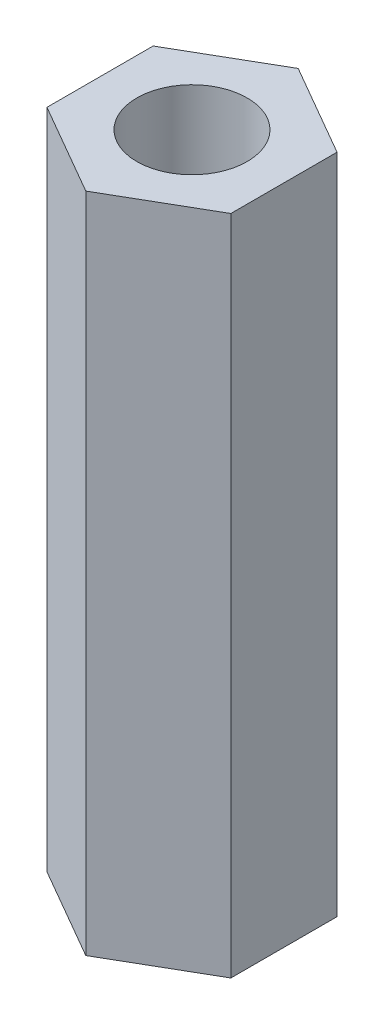
from build123d import *

# Parameters (mm, degrees)
SKETCH_1_R      = 1.5
EXTRUDE_1_DEPTH = 18


with BuildPart() as part:
    # 草圖1 → 填料-伸長1 (new body)
    with BuildSketch(Plane(origin=(0, 0, 0), x_dir=(1, 0, 0), z_dir=(0, 1, 0))):
        Polygon((0, 2.886751346), (-2.5, 1.443375673), (-2.5, -1.443375673), (0, -2.886751346), (2.5, -1.443375673), (2.5, 1.443375673), align=None)
        Circle(SKETCH_1_R, mode=Mode.SUBTRACT)
    extrude(amount=EXTRUDE_1_DEPTH)


solid = part.part
